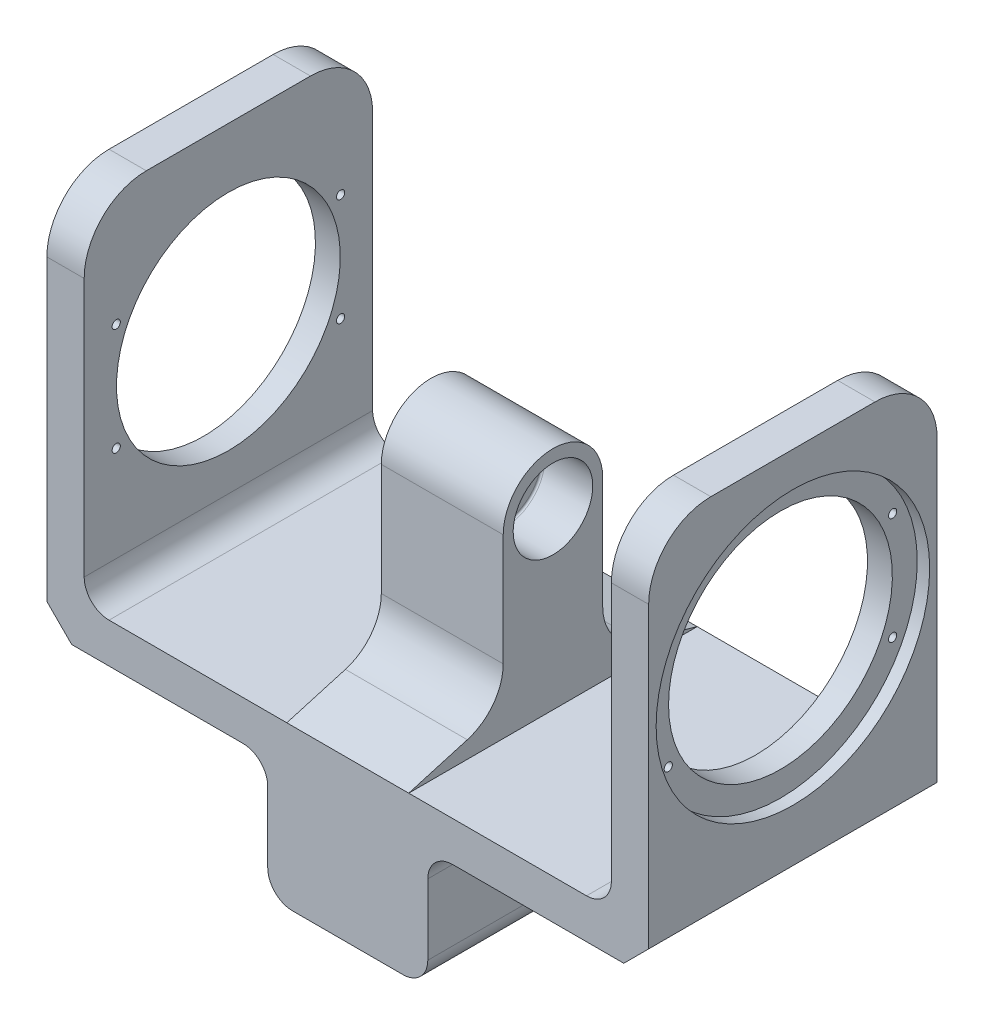
from build123d import *

# Parameters (mm, degrees)
BOSS_EXTRUDE1_DEPTH   = 116
SKETCH5_R             = 16
CUT_EXTRUDE1_DEPTH    = 20
CUT_EXTRUDE2_REACH    = 6.51
SKETCH6_R             = 10
CUT_EXTRUDE4_REACH    = 17
SKETCH8_R             = 45
CUT_EXTRUDE5_DEPTH    = 106
FILLET3_R             = 25
SKETCH21_R            = 55
CUT_EXTRUDE7_DEPTH    = 5
M4X0_7_TAPPED_HOLE1_D = 3.3
FILLET4_R             = 0.8
CHAMFER1_SIZE         = 10
SKETCH25_W            = 64.356
SKETCH25_H            = 48.356
BOSS_EXTRUDE2_DEPTH   = 116
CUT_EXTRUDE8_DEPTH    = 106
FILLET6_R             = 10
FILLET7_R             = 10
FILLET8_R             = 10


with BuildPart() as part:
    # Sketch1 → Boss-Extrude1 (new body)
    with BuildSketch(Plane.XY):
        Polygon((0, 0), (-106, 0), (-121, 0), (-121, 155), (-106, 155), (-106, 16), (-24.51, 16), (-24.51, 107), (0, 107), align=None)
    extrude(amount=-BOSS_EXTRUDE1_DEPTH)

    # Sketch5 → Cut-Extrude1 (cut)
    with BuildSketch(Plane.ZY.offset(24.51)):
        with Locations((-58, 86)):
            Circle(SKETCH5_R)
    extrude(amount=-CUT_EXTRUDE1_DEPTH, mode=Mode.SUBTRACT)

    # Sketch6 → Cut-Extrude2 (cut, up to next)
    with BuildSketch(Plane.ZY.offset(4.51), mode=Mode.PRIVATE) as cut_extrude2_sk1:
        with Locations((-58, 86)):
            Circle(SKETCH6_R)
    cut_extrude2_tool1 = extrude(cut_extrude2_sk1.sketch, amount=-CUT_EXTRUDE2_REACH, mode=Mode.PRIVATE) & part.part
    add(cut_extrude2_tool1.solids().sort_by_distance((-4.51, 86, -58))[0], mode=Mode.SUBTRACT)

    # Sketch8 → Cut-Extrude4 (cut, up to next)
    with BuildSketch(Plane(origin=(-106, 0, 0), x_dir=(0, 0, -1), z_dir=(1, 0, 0)), mode=Mode.PRIVATE) as cut_extrude4_sk1:
        with Locations((58, 86)):
            Circle(SKETCH8_R)
    cut_extrude4_tool1 = extrude(cut_extrude4_sk1.sketch, amount=-CUT_EXTRUDE4_REACH, mode=Mode.PRIVATE) & part.part
    add(cut_extrude4_tool1.solids().sort_by_distance((-106, 86, -58))[0], mode=Mode.SUBTRACT)

    # Sketch10 → Cut-Extrude5 (cut)
    with BuildSketch(Plane(origin=(0, 0, 0), x_dir=(0, 0, -1), z_dir=(1, 0, 0))):
        with BuildLine():
            Line((0, 107), (0, 16))
            Line((0, 16), (23.561161531, 22.820336233))
            ThreePointArc((23.561161531, 22.820336233), (33.987858372, 30.015449722), (38, 42.031621521))
            Line((38, 42.031621521), (38, 87))
            ThreePointArc((38, 87), (43.857864376, 101.142135624), (58, 107))
            Line((58, 107), (0, 107))
        make_face()
        with BuildLine():
            Line((116, 107), (58, 107))
            ThreePointArc((58, 107), (72.142135624, 101.142135624), (78, 87))
            Line((78, 87), (78, 42.031621521))
            ThreePointArc((78, 42.031621521), (82.012141628, 30.015449722), (92.438838469, 22.820336233))
            Line((92.438838469, 22.820336233), (116, 16))
            Line((116, 16), (116, 107))
        make_face()
    extrude(amount=-CUT_EXTRUDE5_DEPTH, mode=Mode.SUBTRACT)

    # Fillet3
    fillet3_edges = [part.edges().sort_by_distance(p)[0] for p in [
        (-113.5, 155, 0),
        (-113.5, 155, -116),
    ]]
    fillet(fillet3_edges, radius=FILLET3_R)

    # Sketch21 → Cut-Extrude7 (cut)
    with BuildSketch(Plane.ZY.offset(121)):
        with Locations((-58, 86)):
            Circle(SKETCH21_R)
    extrude(amount=-CUT_EXTRUDE7_DEPTH, mode=Mode.SUBTRACT)

    # M4x0.7 Tapped Hole1 (through all)
    with Locations(Plane.ZY.offset(116)):
        with Locations((-103.10855484, 107.568919311), (-12.89144516, 107.568919311), (-12.89144516, 64.431080689), (-103.10855484, 64.431080689)):
            Hole(M4X0_7_TAPPED_HOLE1_D / 2)

    # Mirror1: part across plane


with BuildPart() as part_1:
    add(part.part)
    add(part.part.mirror(Plane(origin=(0, 107, -116), x_dir=(0, 0, 1), z_dir=(1, 0, 0))))

    # Fillet4
    fillet4_edges = [part_1.edges().sort_by_distance(p)[0] for p in [
        (4.51, 86, -74),
        (-4.51, 86, -74),
    ]]
    fillet(fillet4_edges, radius=FILLET4_R)

    # Chamfer1
    chamfer1_edges = [part_1.edges().sort_by_distance(p)[0] for p in [
        (-121, 0, -58),
        (121, 0, -58),
    ]]
    chamfer(chamfer1_edges, length=CHAMFER1_SIZE)

    # Sketch25 → Boss-Extrude2 (add)
    with BuildSketch(Plane.XY):
        with Locations((0, -24.178)):
            Rectangle(SKETCH25_W, SKETCH25_H)
    extrude(amount=-BOSS_EXTRUDE2_DEPTH)

    # Sketch27 → Cut-Extrude8 (cut)
    with BuildSketch(Plane(origin=(0, 0, -116), x_dir=(-1, 0, 0), z_dir=(0, 0, -1))):
        with BuildLine():
            Line((-21.05025, -43.356), (21.05025, -43.356))
            ThreePointArc((21.05025, -43.356), (25.383223578, -41.561223578), (27.178, -37.22825))
            Line((27.178, -37.22825), (27.178, 4.87225))
            ThreePointArc((27.178, 4.87225), (25.383223578, 9.205223578), (21.05025, 11))
            Line((21.05025, 11), (-21.05025, 11))
            ThreePointArc((-21.05025, 11), (-25.383223578, 9.205223578), (-27.178, 4.87225))
            Line((-27.178, 4.87225), (-27.178, -37.22825))
            ThreePointArc((-27.178, -37.22825), (-25.383223578, -41.561223578), (-21.05025, -43.356))
        make_face()
    extrude(amount=-CUT_EXTRUDE8_DEPTH, mode=Mode.SUBTRACT)

    # Fillet6
    fillet6_edges = [part_1.edges().sort_by_distance(p)[0] for p in [
        (-32.178, 0, -58),
        (32.178, 0, -58),
    ]]
    fillet(fillet6_edges, radius=FILLET6_R)

    # Fillet7
    fillet7_edges = [part_1.edges().sort_by_distance(p)[0] for p in [
        (-32.178, -48.356, -58),
        (32.178, -48.356, -58),
    ]]
    fillet(fillet7_edges, radius=FILLET7_R)

    # Fillet8
    fillet8_edges = [part_1.edges().sort_by_distance(p)[0] for p in [
        (106, 16, -58),
        (-106, 16, -58),
    ]]
    fillet(fillet8_edges, radius=FILLET8_R)


solid = part_1.part
